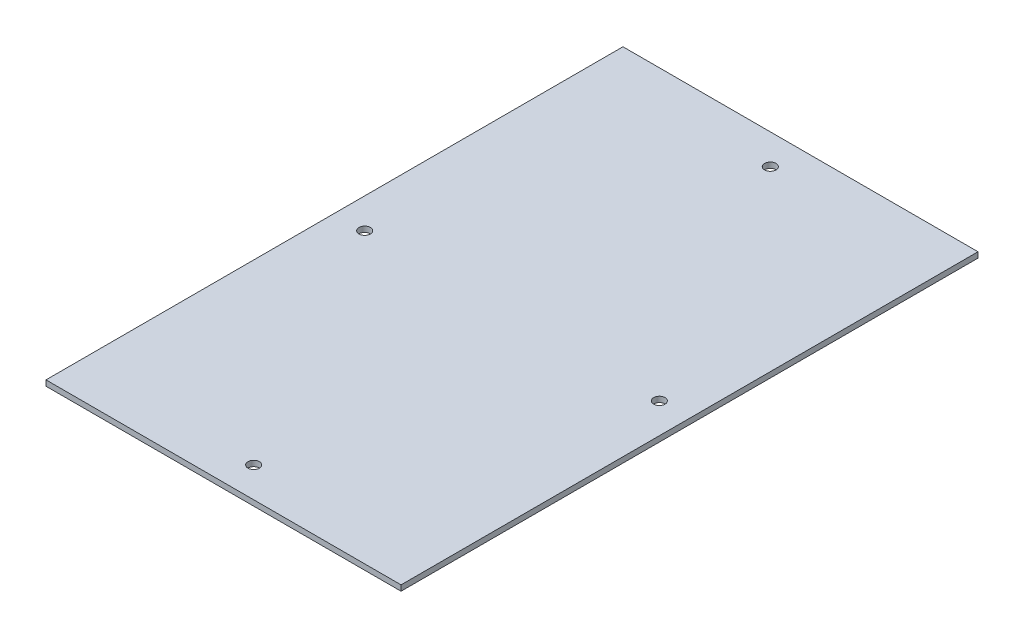
from build123d import *

# Parameters (mm, degrees)
SKETCH1_W           = 203.2
SKETCH1_H           = 330.2
SKETCH1_R           = 3.2639
BOSS_EXTRUDE3_DEPTH = 3.175


with BuildPart() as part:
    # Sketch1 → Boss-Extrude3 (new body)
    with BuildSketch(Plane(origin=(0, 0, 0), x_dir=(1, 0, 0), z_dir=(0, 1, 0))):
        with Locations((101.6, -165.1)):
            Rectangle(SKETCH1_W, SKETCH1_H)
        with Locations((17.272, -165.1)):
            Circle(SKETCH1_R, mode=Mode.SUBTRACT)
        with Locations((101.6, -17.272)):
            Circle(SKETCH1_R, mode=Mode.SUBTRACT)
        with Locations((101.6, -312.928)):
            Circle(SKETCH1_R, mode=Mode.SUBTRACT)
        with Locations((185.928, -165.1)):
            Circle(SKETCH1_R, mode=Mode.SUBTRACT)
    extrude(amount=BOSS_EXTRUDE3_DEPTH)


solid = part.part
